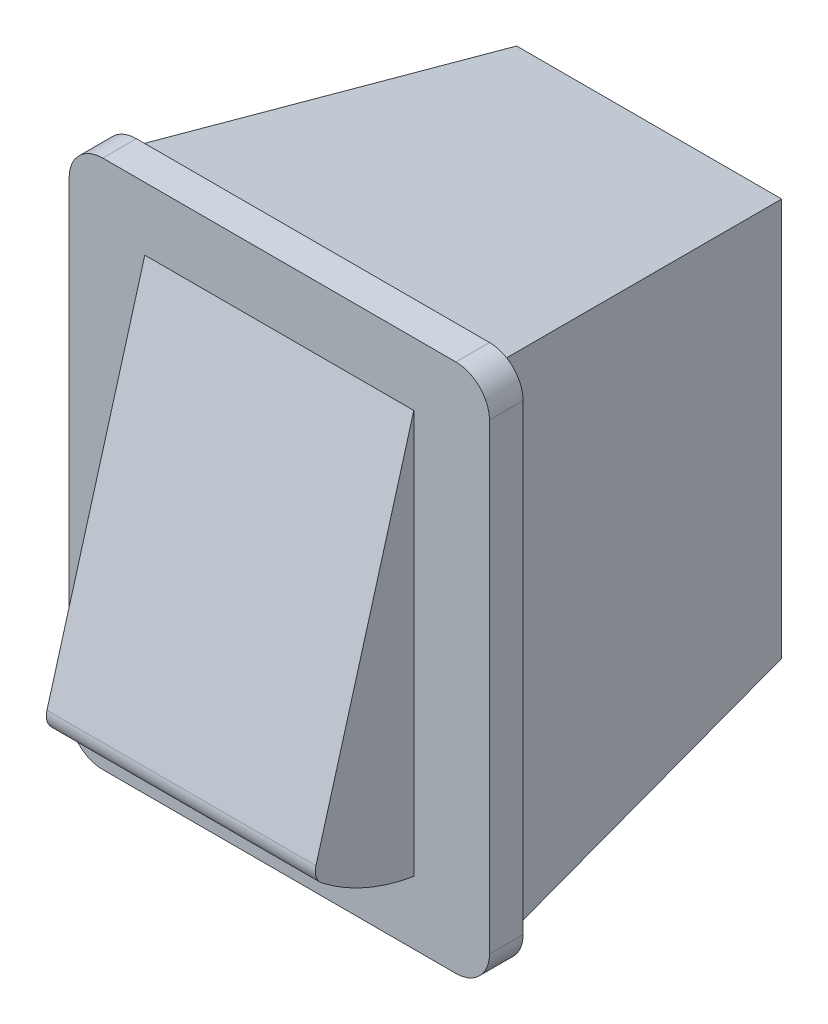
from build123d import *

# Parameters (mm, degrees)
BOSS_EXTRUDE1_DEPTH = 2
BOSS_EXTRUDE2_DEPTH = 8
SKETCH3_W           = 22.1
SKETCH3_H           = 30
BOSS_EXTRUDE3_DEPTH = 20
BOSS_EXTRUDE3_TAPER = 9


with BuildPart() as part:
    # Sketch1 → Boss-Extrude1 (new body)
    with BuildSketch(Plane.XY):
        with BuildLine():
            Line((-10.5, -15.75), (10.5, -15.75))
            ThreePointArc((10.5, -15.75), (11.914213562, -15.164213562), (12.5, -13.75))
            Line((12.5, -13.75), (12.5, 13.75))
            ThreePointArc((12.5, 13.75), (11.914213562, 15.164213562), (10.5, 15.75))
            Line((10.5, 15.75), (-10.5, 15.75))
            ThreePointArc((-10.5, 15.75), (-11.914213562, 15.164213562), (-12.5, 13.75))
            Line((-12.5, 13.75), (-12.5, -13.75))
            ThreePointArc((-12.5, -13.75), (-11.914213562, -15.164213562), (-10.5, -15.75))
        make_face()
    extrude(amount=BOSS_EXTRUDE1_DEPTH)

    # Sketch2 → Boss-Extrude2 (add, symmetric)
    with BuildSketch(Plane(origin=(0, 0, 0), x_dir=(0, 0, -1), z_dir=(1, 0, 0))):
        with BuildLine():
            Line((-2, 12.000372018), (-2, -12.000372018))
            ThreePointArc((-2, -12.000372018), (-4.886867761, -11.141250022), (-7.474198634, -9.599233477))
            ThreePointArc((-7.474198634, -9.599233477), (-7.810172539, -9.12144706), (-7.821933208, -8.537477873))
            Line((-7.821933208, -8.537477873), (-2, 12.000372018))
        make_face()
    extrude(amount=BOSS_EXTRUDE2_DEPTH, both=True)

    # Sketch3 → Boss-Extrude3 (add)
    with BuildSketch(Plane(origin=(0, 0, 0), x_dir=(-1, 0, 0), z_dir=(0, 0, -1))):
        Rectangle(SKETCH3_W, SKETCH3_H)
    extrude(amount=BOSS_EXTRUDE3_DEPTH, taper=BOSS_EXTRUDE3_TAPER)


solid = part.part
